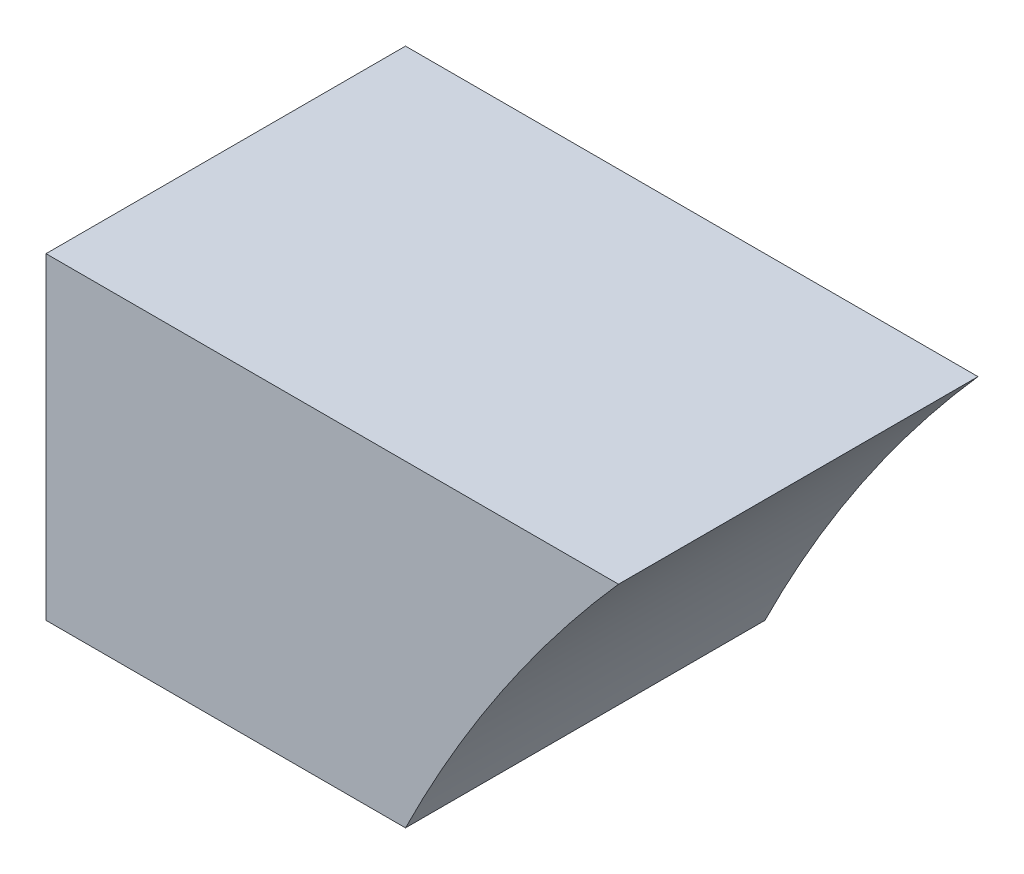
from build123d import *

# Parameters (mm, degrees)
EXTRUDE_1_DEPTH = 480
SCALE_1_SCALE   = 1.3


with BuildPart() as part:
    # 草图1 → 凸台-拉伸1 (new body)
    with BuildSketch(Plane.XY):
        with BuildLine():
            Line((-8442.584105349, 4688), (-7962.584105349, 4688))
            ThreePointArc((-7962.584105349, 4688), (-7883.943917736, 4831.891322342), (-7793.3126292, 4968.547684402))
            ThreePointArc((-7793.3126292, 4968.547684402), (-7737.474510483, 5041.653065761), (-7678.198873592, 5112))
            Line((-7678.198873592, 5112), (-8158.198873592, 5112))
            Line((-8158.198873592, 5112), (-8442.584105349, 5112))
            Line((-8442.584105349, 5112), (-8442.584105349, 4688))
        make_face()
    extrude(amount=EXTRUDE_1_DEPTH)


with BuildPart() as part_1:
    # 缩放比例1: scaled about (0, 0, 0)
    add(part.part.scale(SCALE_1_SCALE))


solid = part_1.part
